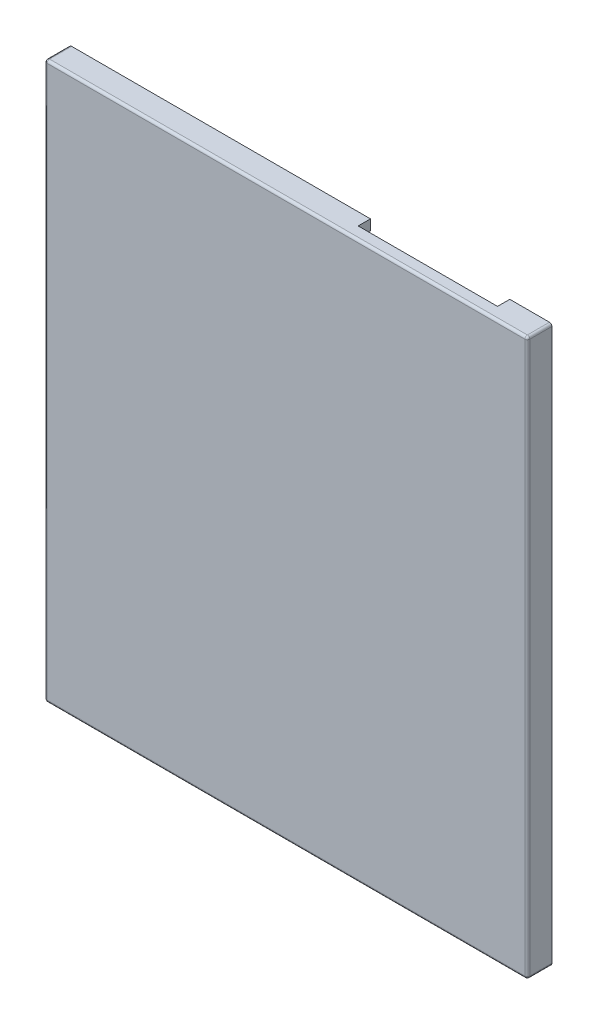
from build123d import *

# Parameters (mm, degrees)
SKETCH_1_W          = 56.5
SKETCH_1_H          = 65.5
EXTRUDE_1_DEPTH     = 1.5
SKETCH_2_W          = 59
SKETCH_2_H          = 68
SKETCH_2_W_2        = 56.5
SKETCH_2_H_2        = 65.5
EXTRUDE_2_DEPTH     = 3
FILLET_1_R          = 0.3
SKETCH_4_W          = 25
SKETCH_4_H          = 5
SKETCH_4_W_2        = 30.699386717
SKETCH_4_H_2        = 8.5
SKETCH_4_W_3        = 20
SKETCH_4_H_3        = 30
CUT_EXTRUDE_1_DEPTH = 1
SKETCH_5_W          = 17.035074377
SKETCH_5_H          = 1.25
CUT_EXTRUDE_2_DEPTH = 1.5


with BuildPart() as part:
    # 草图1 → 凸台-拉伸1 (new body)
    with BuildSketch(Plane.XY):
        Rectangle(SKETCH_1_W, SKETCH_1_H)
    extrude(amount=EXTRUDE_1_DEPTH)

    # 草图2 → 凸台-拉伸2 (add)
    with BuildSketch(Plane.XY.offset(1.5)):
        Rectangle(SKETCH_2_W, SKETCH_2_H)
        Rectangle(SKETCH_2_W_2, SKETCH_2_H_2, mode=Mode.SUBTRACT)
    extrude(amount=-EXTRUDE_2_DEPTH)

    # 圆角1
    fillet_1_edges = [part.edges().sort_by_distance(p)[0] for p in [
        (29.5, 34, 0),
        (29.5, -34, 0),
        (-29.5, -34, 0),
        (-29.5, 34, 0),
        (29.5, 0, 1.5),
        (0, 34, 1.5),
        (-29.5, 0, 1.5),
        (0, -34, 1.5),
    ]]
    fillet(fillet_1_edges, radius=FILLET_1_R)

    # 草图4 → 切除-拉伸1 (cut)
    with BuildSketch(Plane(origin=(0, 0, 0), x_dir=(-1, 0, 0), z_dir=(0, 0, -1))):
        with Locations((7.75, 13.75)):
            Rectangle(SKETCH_4_W, SKETCH_4_H)
        with Locations((5.900306641, 5.5)):
            Rectangle(SKETCH_4_W_2, SKETCH_4_H_2)
        with Locations((11.25, -15.75)):
            Rectangle(SKETCH_4_W_3, SKETCH_4_H_3)
    extrude(amount=-CUT_EXTRUDE_1_DEPTH, mode=Mode.SUBTRACT)

    # 草图5 → 切除-拉伸2 (cut)
    with BuildSketch(Plane(origin=(0, 0, -1.5), x_dir=(-1, 0, 0), z_dir=(0, 0, -1))):
        with Locations((-15.836199448, 33.375)):
            Rectangle(SKETCH_5_W, SKETCH_5_H)
    extrude(amount=-CUT_EXTRUDE_2_DEPTH, mode=Mode.SUBTRACT)


solid = part.part
